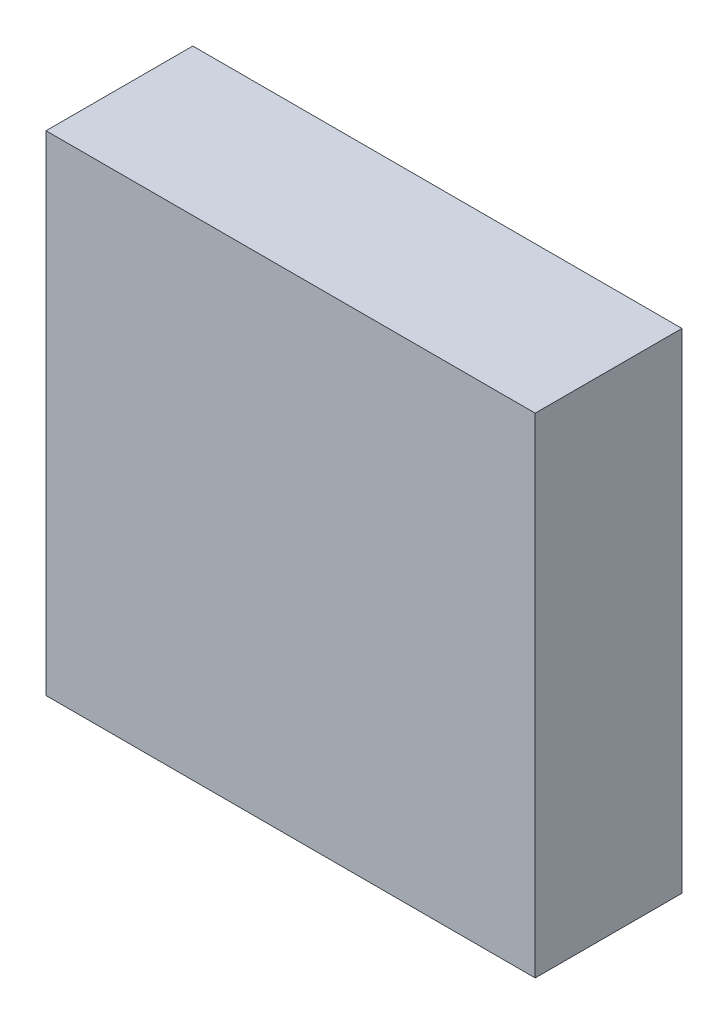
from build123d import *

# Parameters (mm, degrees)
SKETCH1_W           = 100
SKETCH1_H           = 100
BOSS_EXTRUDE1_DEPTH = 30


with BuildPart() as part:
    # Sketch1 → Boss-Extrude1 (new body)
    with BuildSketch(Plane.XY):
        Rectangle(SKETCH1_W, SKETCH1_H)
    extrude(amount=BOSS_EXTRUDE1_DEPTH)


solid = part.part
